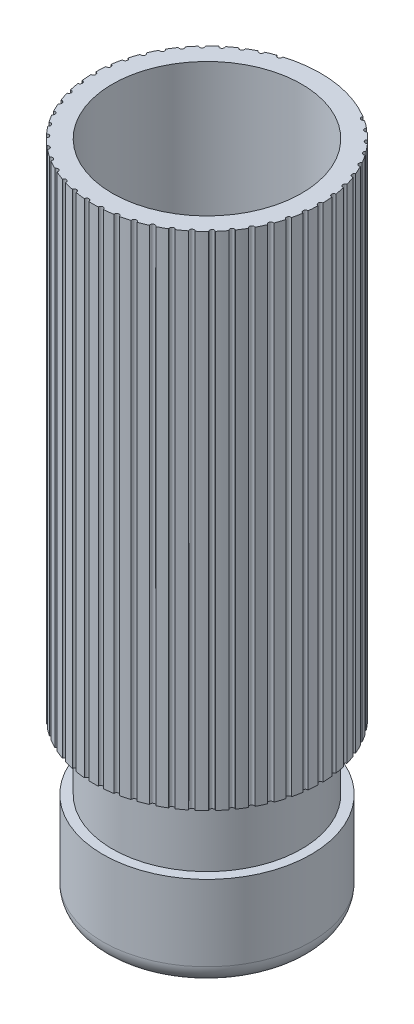
from build123d import *

# Parameters (mm, degrees)
SKETCH_1_R               = 12
EXTRUDE_1_DEPTH          = 50
SHELL_3_T                = -2
SKETCH_2_R               = 12
EXTRUDE_2_DEPTH          = 20
FILLET_1_R               = 2
SKETCH_5_R               = 0.25
CUT_EXTRUDE_1_DEPTH      = 54
PATTERN_CIRCULAR_1_COUNT = 50


with BuildPart() as part:
    # 草图1 → 凸台-拉伸1 (new body)
    with BuildSketch(Plane(origin=(0, 0, 0), x_dir=(1, 0, 0), z_dir=(0, 1, 0))):
        with Locations(Location((0, 0, 0), (0, 0, 270))):
            Circle(SKETCH_1_R)
    extrude(amount=EXTRUDE_1_DEPTH)

    # 抽壳3
    shell_3_openings = [part.faces().sort_by_distance(p)[0] for p in [
        (0, 50, 0),
    ]]
    offset(amount=SHELL_3_T, openings=shell_3_openings, kind=Kind.INTERSECTION)

    # 草图2 → 凸台-拉伸2 (add)
    with BuildSketch(Plane.XZ):
        with Locations(Location((0, 0, 0), (0, 0, 270))):
            Circle(SKETCH_2_R)
    extrude(amount=EXTRUDE_2_DEPTH)

    # 草图3 → 切除-旋转1 (revolve, cut)
    with BuildSketch(Plane.XY, mode=Mode.PRIVATE) as cut_revolve_1_sk:
        Polygon((11, -10), (11, -20), (12.743043998, -20), (12.743043998, -3), (10, -3), (10, -10), align=None)
    revolve(cut_revolve_1_sk.sketch.rotate(Axis((0, -0.535575004, 0), (0, -1, 0)), 180), axis=Axis((0, -0.535575004, 0), (0, -1, 0)), mode=Mode.SUBTRACT)

    # 圆角1
    fillet_1_edges = [part.edges().sort_by_distance(p)[0] for p in [
        (11, -20, 0),
    ]]
    fillet(fillet_1_edges, radius=FILLET_1_R)

    # 草图5 → 切除-拉伸1 (cut)
    with BuildSketch(Plane(origin=(0, 50, 0), x_dir=(1, 0, 0), z_dir=(0, 1, 0))):
        with Locations((12, 0)):
            Circle(SKETCH_5_R)
    cut_extrude_1 = extrude(amount=-CUT_EXTRUDE_1_DEPTH, mode=Mode.SUBTRACT)

    # 阵列(圆周)1: 切除-拉伸1 ×50 about axis, 6 skipped
    pattern_circular_1_axis = Axis((0, 0, 0), (0, -1, 0))
    add([cut_extrude_1.rotate(pattern_circular_1_axis, i * 360 / PATTERN_CIRCULAR_1_COUNT) for i in range(1, PATTERN_CIRCULAR_1_COUNT) if i not in (36, 37, 38, 39, 40, 41)], mode=Mode.SUBTRACT)


solid = part.part
